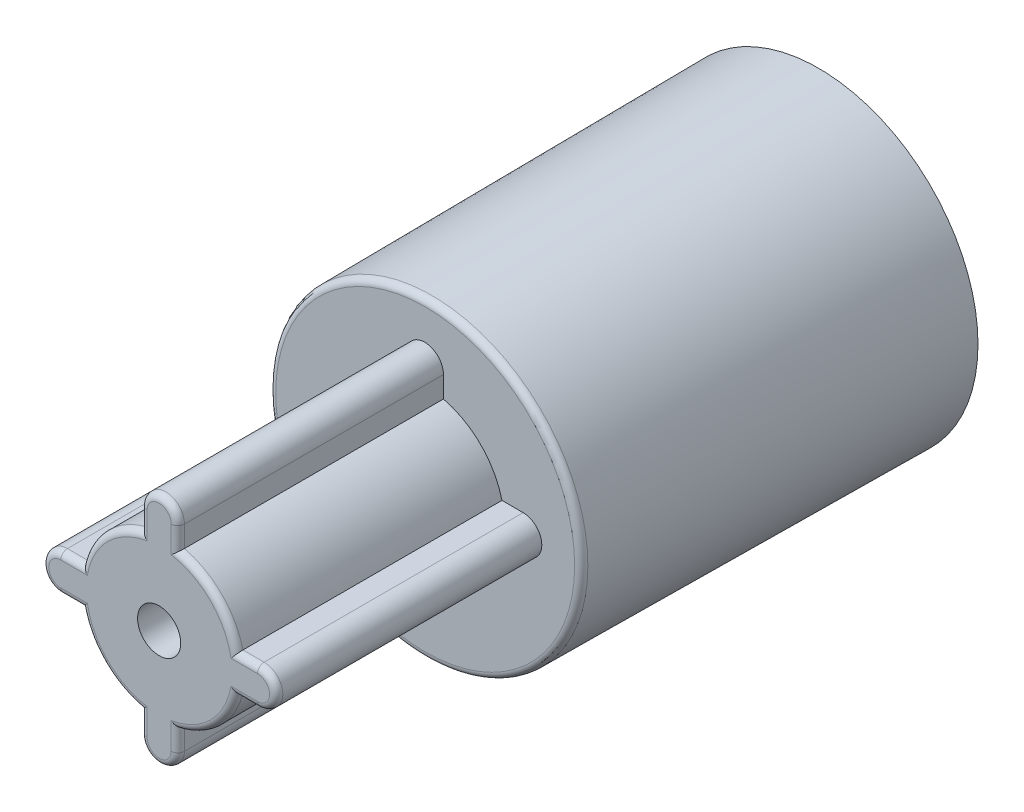
from build123d import *

# Parameters (mm, degrees)
SKETCH1_R           = 9.6
BASE_EXTRUDE_DEPTH  = 23.7
CUT_EXTRUDE1_DEPTH  = 21.7
BOSS_EXTRUDE1_DEPTH = 16
SKETCH4_R           = 1.3
CUT_EXTRUDE2_DEPTH  = 40.7
FILLET4_R           = 0.4


with BuildPart() as part:
    # Sketch1 → Base-Extrude (new body)
    with BuildSketch(Plane.XY):
        Circle(SKETCH1_R)
    extrude(amount=BASE_EXTRUDE_DEPTH)

    # Sketch2 → Cut-Extrude1 (cut)
    with BuildSketch(Plane(origin=(0, 0, 0), x_dir=(-1, 0, 0), z_dir=(0, 0, -1))):
        with BuildLine():
            Line((1.151331339, 6.016608995), (1.151331339, 4.741608995))
            ThreePointArc((1.151331339, 4.741608995), (3.409837287, 3.474244057), (4.677202225, 1.215738109))
            Line((4.677202225, 1.215738109), (5.952202225, 1.215738109))
            ThreePointArc((5.952202225, 1.215738109), (6.747697354, 0.886233238), (7.077202225, 0.090738109))
            ThreePointArc((7.077202225, 0.090738109), (6.747697354, -0.70475702), (5.952202225, -1.034261891))
            Line((5.952202225, -1.034261891), (4.677202225, -1.034261891))
            ThreePointArc((4.677202225, -1.034261891), (3.409837287, -3.292767839), (1.151331339, -4.560132777))
            Line((1.151331339, -4.560132777), (1.151331339, -5.835132777))
            ThreePointArc((1.151331339, -5.835132777), (0.026331339, -6.960132777), (-1.098668661, -5.835132777))
            Line((-1.098668661, -5.835132777), (-1.098668661, -4.560132777))
            ThreePointArc((-1.098668661, -4.560132777), (-3.357174609, -3.292767839), (-4.624539548, -1.034261891))
            Line((-4.624539548, -1.034261891), (-5.899539548, -1.034261891))
            ThreePointArc((-5.899539548, -1.034261891), (-6.695034676, -0.70475702), (-7.024539548, 0.090738109))
            ThreePointArc((-7.024539548, 0.090738109), (-6.695034676, 0.886233238), (-5.899539548, 1.215738109))
            Line((-5.899539548, 1.215738109), (-4.624539548, 1.215738109))
            ThreePointArc((-4.624539548, 1.215738109), (-3.357174609, 3.474244057), (-1.098668661, 4.741608995))
            Line((-1.098668661, 4.741608995), (-1.098668661, 6.016608995))
            ThreePointArc((-1.098668661, 6.016608995), (-0.76916379, 6.812104124), (0.026331339, 7.141608995))
            ThreePointArc((0.026331339, 7.141608995), (0.821826467, 6.812104124), (1.151331339, 6.016608995))
        make_face()
    extrude(amount=-CUT_EXTRUDE1_DEPTH, mode=Mode.SUBTRACT)

    # Sketch3 → Boss-Extrude1 (add)
    with BuildSketch(Plane.XY.offset(23.7)):
        with BuildLine():
            Line((-1.151331339, 6.016608995), (-1.151331339, 4.741608995))
            ThreePointArc((-1.151331339, 4.741608995), (-3.409837287, 3.474244057), (-4.677202225, 1.215738109))
            Line((-4.677202225, 1.215738109), (-5.952202225, 1.215738109))
            ThreePointArc((-5.952202225, 1.215738109), (-6.747697354, 0.886233238), (-7.077202225, 0.090738109))
            ThreePointArc((-7.077202225, 0.090738109), (-6.747697354, -0.70475702), (-5.952202225, -1.034261891))
            Line((-5.952202225, -1.034261891), (-4.677202225, -1.034261891))
            ThreePointArc((-4.677202225, -1.034261891), (-3.409837287, -3.292767839), (-1.151331339, -4.560132777))
            Line((-1.151331339, -4.560132777), (-1.151331339, -5.835132777))
            ThreePointArc((-1.151331339, -5.835132777), (-0.026331339, -6.960132777), (1.098668661, -5.835132777))
            Line((1.098668661, -5.835132777), (1.098668661, -4.560132777))
            ThreePointArc((1.098668661, -4.560132777), (3.357174609, -3.292767839), (4.624539548, -1.034261891))
            Line((4.624539548, -1.034261891), (5.899539548, -1.034261891))
            ThreePointArc((5.899539548, -1.034261891), (6.695034676, -0.70475702), (7.024539548, 0.090738109))
            ThreePointArc((7.024539548, 0.090738109), (6.695034676, 0.886233238), (5.899539548, 1.215738109))
            Line((5.899539548, 1.215738109), (4.624539548, 1.215738109))
            ThreePointArc((4.624539548, 1.215738109), (3.357174609, 3.474244057), (1.098668661, 4.741608995))
            Line((1.098668661, 4.741608995), (1.098668661, 6.016608995))
            ThreePointArc((1.098668661, 6.016608995), (0.76916379, 6.812104124), (-0.026331339, 7.141608995))
            ThreePointArc((-0.026331339, 7.141608995), (-0.821826467, 6.812104124), (-1.151331339, 6.016608995))
        make_face()
    extrude(amount=BOSS_EXTRUDE1_DEPTH)

    # Sketch4 → Cut-Extrude2 (cut, through all)
    with BuildSketch(Plane.XY.offset(39.7)):
        with Locations((-0.026331339, 0.090738109)):
            Circle(SKETCH4_R)
    extrude(amount=-CUT_EXTRUDE2_DEPTH, mode=Mode.SUBTRACT)

    # Sketch5 → Cut-Revolve1 (revolve, cut)
    with BuildSketch(Plane(origin=(0, 0, 0), x_dir=(0, 0, -1), z_dir=(1, 0, 0))):
        Polygon((0, 9.6), (-23.7, 9.4), (-23.7, 9.6), align=None)
    revolve(axis=Axis((0, 0, 0), (0, 0, 1)), mode=Mode.SUBTRACT)

    # Fillet4
    fillet4_edges = [part.edges().sort_by_distance(p)[0] for p in [
        (0, -9.4, 23.7),
        (-5.314702225, 1.215738109, 39.7),
        (-1.151331339, -5.197632777, 39.7),
        (1.098668661, -5.197632777, 39.7),
        (5.262039548, -1.034261891, 39.7),
        (1.098668661, 5.379108995, 39.7),
        (-0.026331339, 7.141608995, 39.7),
        (-1.151331339, 5.379108995, 39.7),
        (-3.409837287, 3.474244057, 39.7),
        (-7.077202225, 0.090738109, 39.7),
        (-5.314702225, -1.034261891, 39.7),
        (-3.409837287, -3.292767839, 39.7),
        (-0.026331339, -6.960132777, 39.7),
        (3.357174609, -3.292767839, 39.7),
        (7.024539548, 0.090738109, 39.7),
        (5.262039548, 1.215738109, 39.7),
        (3.357174609, 3.474244057, 39.7),
    ]]
    fillet(fillet4_edges, radius=FILLET4_R)


solid = part.part
